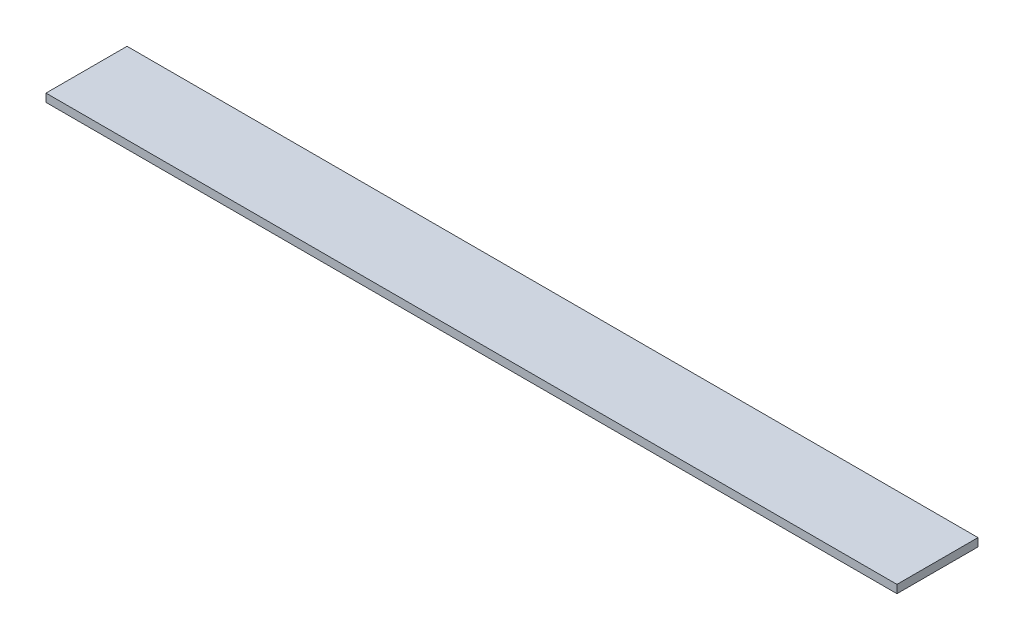
from build123d import *

# Parameters (mm, degrees)
ESQUISSE1_W      = 1050
ESQUISSE1_H      = 100
EXTRUSION1_DEPTH = 10


with BuildPart() as part:
    # Esquisse1 → Extrusion1 (new body)
    with BuildSketch(Plane(origin=(0, 0, 0), x_dir=(1, 0, 0), z_dir=(0, 1, 0))):
        with Locations((525, 50)):
            Rectangle(ESQUISSE1_W, ESQUISSE1_H)
    extrude(amount=EXTRUSION1_DEPTH)


solid = part.part
